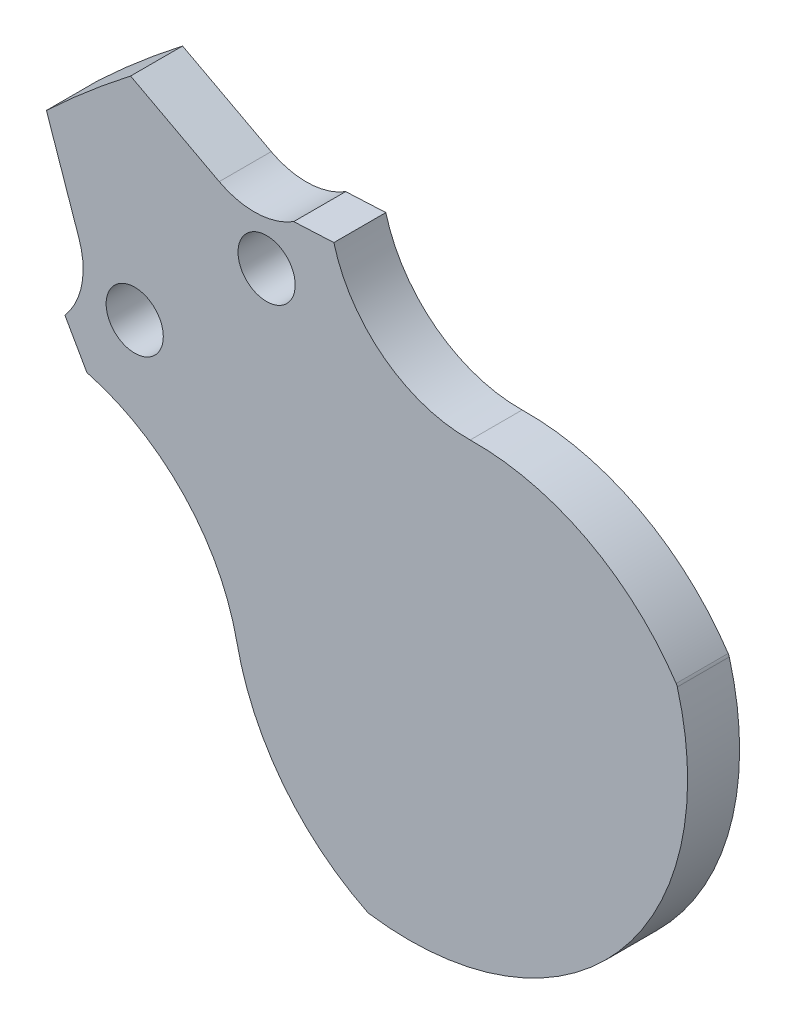
from build123d import *

# Parameters (mm, degrees)
BOSS_EXTRUDE1_DEPTH     = 115
BOSS_EXTRUDE2_DEPTH     = 3
SKETCH4_R               = 1.65
CUT_EXTRUDE1_DEPTH      = 147.999004413
CUT_EXTRUDE2_DEPTH      = 147.999004413
CUT_EXTRUDE_THIN1_DEPTH = 147.999004413
CUT_EXTRUDE3_DEPTH      = 147.999004413


with BuildPart() as part:
    # Sketch1 → Boss-Extrude1 (new body)
    with BuildSketch(Plane(origin=(0, 0, 0), x_dir=(0, 1, 0), z_dir=(0, 0, 1))):
        with BuildLine():
            Line((66.793011614, 25.63943495), (62.125109481, 23.847595202))
            ThreePointArc((62.125109481, 23.847595202), (50.18784505, 43.696878999), (32.170193606, 58.252173078))
            Line((32.170193606, 58.252173078), (34.587369472, 62.629073903))
            ThreePointArc((34.587369472, 62.629073903), (53.95881545, 46.980136869), (66.793011614, 25.63943495))
        make_face()
    extrude(amount=BOSS_EXTRUDE1_DEPTH)

    # Sketch3 → Boss-Extrude2 (add)
    with BuildSketch(Plane(origin=(0, 0, 0), x_dir=(0, 1, 0), z_dir=(0, 0, 1))):
        with BuildLine():
            ThreePointArc((37.772226983, 9.055581263), (42.402339681, 14.205235152), (43.997873295, 20.944014808))
            ThreePointArc((43.997873295, 20.944014808), (49.930251766, 28.811968202), (58.997685125, 24.954578252))
            ThreePointArc((58.997685125, 24.954578252), (60.351321071, 23.807583941), (62.125109481, 23.847595202))
            ThreePointArc((62.125109481, 23.847595202), (50.18784505, 43.696878999), (32.170193606, 58.252173078))
            ThreePointArc((32.170193606, 58.252173078), (31.867825608, 56.602303211), (32.676329677, 55.132671232))
            ThreePointArc((32.676329677, 55.132671232), (36.307290349, 43.066223982), (27.152640183, 34.407390053))
            ThreePointArc((27.152640183, 34.407390053), (21.43315886, 31.77290535), (17.44684462, 26.898248947))
            ThreePointArc((17.44684462, 26.898248947), (17.417631935, 26.825058047), (17.400281887, 26.748186307))
            ThreePointArc((17.400281887, 26.748186307), (22.701893313, 12.386399614), (37.629460858, 8.989970916))
            ThreePointArc((37.629460858, 8.989970916), (37.70343721, 9.017133171), (37.772226983, 9.055581263))
        make_face()
    extrude(amount=BOSS_EXTRUDE2_DEPTH)

    # Sketch4 → Cut-Extrude1 (cut, through all)
    with BuildSketch(Plane(origin=(0, 0, 0), x_dir=(0, 1, 0), z_dir=(0, 0, 1))):
        with Locations((40.305086528, 40.305086528)):
            Circle(SKETCH4_R)
        with Locations((46.691666524, 32.693856872)):
            Circle(SKETCH4_R)
    extrude(amount=CUT_EXTRUDE1_DEPTH, mode=Mode.SUBTRACT)

    # Sketch6 → Cut-Extrude2 (cut, through all)
    with BuildSketch(Plane(origin=(0, 0, 0), x_dir=(0, 1, 0), z_dir=(0, 0, 1))):
        with BuildLine():
            Line((52.744660964, 40.57385568), (49.933401851, 35.286646265))
            ThreePointArc((49.933401851, 35.286646265), (50.072999838, 31.289082957), (53.604790209, 29.411196706))
            Line((53.604790209, 29.411196706), (59.589277435, 29.620179604))
            ThreePointArc((59.589277435, 29.620179604), (56.433360559, 35.263477438), (52.744660964, 40.57385568))
        make_face()
        with BuildLine():
            Line((38.577322779, 54.222017596), (37.434732749, 48.343901467))
            ThreePointArc((37.434732749, 48.343901467), (38.737005367, 44.561827164), (42.663514101, 43.798591183))
            Line((42.663514101, 43.798591183), (48.32540701, 45.748137255))
            ThreePointArc((48.32540701, 45.748137255), (43.657448084, 50.222149016), (38.577322779, 54.222017596))
        make_face()
    extrude(amount=CUT_EXTRUDE2_DEPTH, mode=Mode.SUBTRACT)

    # Sketch6_4 → Cut-Extrude-Thin1 (cut, through all)
    # profile 1 of 2: a face of its own
    with BuildSketch(Plane(origin=(0, 0, 0), x_dir=(0, 1, 0), z_dir=(0, 0, 1))):
        with BuildLine():
            Line((60.063470687, 29.336555934), (53.615260058, 29.111379457))
            ThreePointArc((53.615260058, 29.111379457), (49.818585409, 31.130107177), (49.668517573, 35.427487734))
            Line((49.668517573, 35.427487734), (52.697614338, 41.124390185))
            ThreePointArc((52.697614338, 41.124390185), (56.687774988, 35.422453218), (60.063470687, 29.336555934))
        make_face()
        with BuildLine():
            Line((59.589277435, 29.620179604), (53.604790209, 29.411196706))
            ThreePointArc((53.604790209, 29.411196706), (50.072999838, 31.289082957), (49.933401851, 35.286646265))
            Line((49.933401851, 35.286646265), (52.744660964, 40.57385568))
            ThreePointArc((52.744660964, 40.57385568), (56.433360559, 35.263477438), (59.589277435, 29.620179604))
        make_face(mode=Mode.SUBTRACT)
    # profile 2 of 2: a face of its own
    with BuildSketch(Plane(origin=(0, 0, 0), x_dir=(0, 1, 0), z_dir=(0, 0, 1))):
        with BuildLine():
            Line((48.861803808, 45.61554728), (42.761184547, 43.51493561))
            ThreePointArc((42.761184547, 43.51493561), (38.540187658, 44.33541429), (37.140244594, 48.401144165))
            Line((37.140244594, 48.401144165), (38.371371155, 54.734741259))
            ThreePointArc((38.371371155, 54.734741259), (43.854265793, 50.44856189), (48.861803808, 45.61554728))
        make_face()
        with BuildLine():
            Line((48.32540701, 45.748137255), (42.663514101, 43.798591183))
            ThreePointArc((42.663514101, 43.798591183), (38.737005367, 44.561827164), (37.434732749, 48.343901467))
            Line((37.434732749, 48.343901467), (38.577322779, 54.222017596))
            ThreePointArc((38.577322779, 54.222017596), (43.657448084, 50.222149016), (48.32540701, 45.748137255))
        make_face(mode=Mode.SUBTRACT)
    extrude(amount=CUT_EXTRUDE_THIN1_DEPTH, mode=Mode.SUBTRACT)

    # Sketch7 → Cut-Extrude3 (cut, through all)
    with BuildSketch(Plane(origin=(0, 0, 0), x_dir=(0, 1, 0), z_dir=(0, 0, 1))):
        with BuildLine():
            Line((48.240089186, 45.401473768), (38.540187658, 44.33541429))
            Line((38.540187658, 44.33541429), (36.307290349, 43.066223982))
            Line((36.307290349, 43.066223982), (22.600693744, 60.972682424))
            Line((22.600693744, 60.972682424), (52.388918832, 72.501111316))
            Line((52.388918832, 72.501111316), (73.007988399, 34.26459203))
            Line((73.007988399, 34.26459203), (68.951063276, 18.611622597))
            Line((68.951063276, 18.611622597), (52.388918832, 26.438107314))
            Line((52.388918832, 26.438107314), (49.930251766, 28.811968202))
            Line((49.930251766, 28.811968202), (49.818585409, 31.130107177))
            Line((49.818585409, 31.130107177), (52.388918832, 40.543818378))
            ThreePointArc((52.388918832, 40.543818378), (50.373093191, 43.022685962), (48.240089186, 45.401473768))
        make_face()
    extrude(amount=CUT_EXTRUDE3_DEPTH, mode=Mode.SUBTRACT)


solid = part.part
